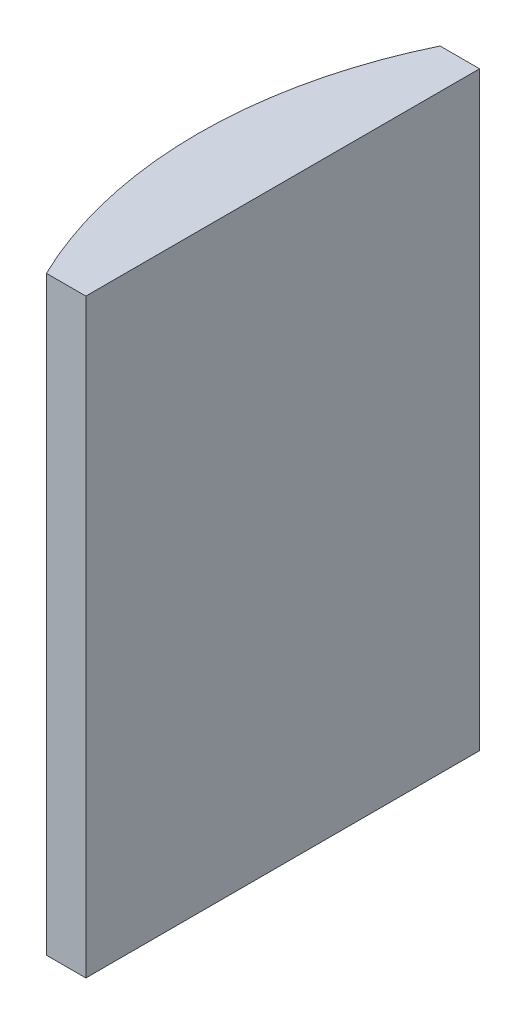
from build123d import *

# Parameters (mm, degrees)
EXTRUDE_1_DEPTH = 30


with BuildPart() as part:
    # 草图1 → 凸台-拉伸1 (new body)
    with BuildSketch(Plane(origin=(0, 0, 0), x_dir=(1, 0, 0), z_dir=(0, 1, 0))):
        with BuildLine():
            Line((-16.268238637, 10), (-14.264795665, 10))
            Line((-14.264795665, 10), (-14.264795665, -10))
            Line((-14.264795665, -10), (-16.268238637, -10))
            ThreePointArc((-16.268238637, -10), (-18.564795665, 0), (-16.268238637, 10))
        make_face()
    extrude(amount=EXTRUDE_1_DEPTH)


solid = part.part
